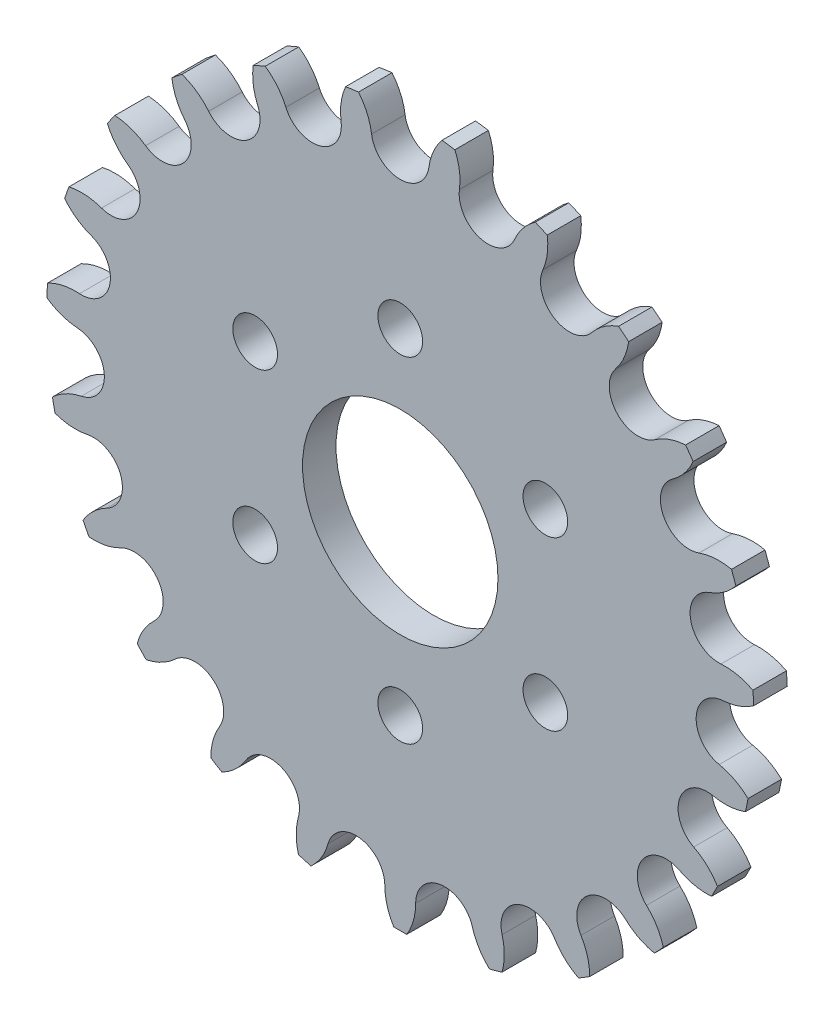
from build123d import *

# Parameters (mm, degrees)
EXTRUDE_1_DEPTH          = 6
PATTERN_CIRCULAR_1_COUNT = 23
SKETCH_3_R               = 17.5
SKETCH_3_R_2             = 4
CUT_EXTRUDE_1_DEPTH      = 7


with BuildPart() as part:
    # Эскиз2 → Бобышка-Вытянуть1 (new body)
    with BuildSketch(Plane.XY):
        with BuildLine():
            Line((0, 0), (0, 53.112541182))
            ThreePointArc((0, 53.112541182), (3.404315056, 54.38830771), (5.1317532, 57.587197939))
            ThreePointArc((5.1317532, 57.587197939), (5.93051423, 60.421485378), (7.471942626, 62.930509685))
            ThreePointArc((7.471942626, 62.930509685), (8.629226577, 62.782285913), (9.783585596, 62.612781672))
            ThreePointArc((9.783585596, 62.612781672), (10.590926988, 59.780926389), (10.595386193, 56.836238869))
            ThreePointArc((10.595386193, 56.836238869), (11.39571599, 53.289914934), (14.329592119, 51.142984079))
            Line((14.329592119, 51.142984079), (0, 0))
        make_face()
    extrude_1 = extrude(amount=EXTRUDE_1_DEPTH)

    # Круговой массив1: Бобышка-Вытянуть1 ×23 about axis
    pattern_circular_1_axis = Axis((0, 0, 0), (0, 0, 1))
    for i in range(1, PATTERN_CIRCULAR_1_COUNT):
        add(extrude_1.rotate(pattern_circular_1_axis, i * 360 / PATTERN_CIRCULAR_1_COUNT))

    # Эскиз3 → Вырез-Вытянуть1 (cut, through all)
    with BuildSketch(Plane.XY.offset(6)):
        Circle(SKETCH_3_R)
        with Locations((0, 30)):
            Circle(SKETCH_3_R_2)
        with Locations((25.980762114, 15)):
            Circle(SKETCH_3_R_2)
        with Locations((25.980762114, -15)):
            Circle(SKETCH_3_R_2)
        with Locations((0, -30)):
            Circle(SKETCH_3_R_2)
        with Locations((-25.980762114, -15)):
            Circle(SKETCH_3_R_2)
        with Locations((-25.980762114, 15)):
            Circle(SKETCH_3_R_2)
    extrude(amount=-CUT_EXTRUDE_1_DEPTH, mode=Mode.SUBTRACT)


solid = part.part
